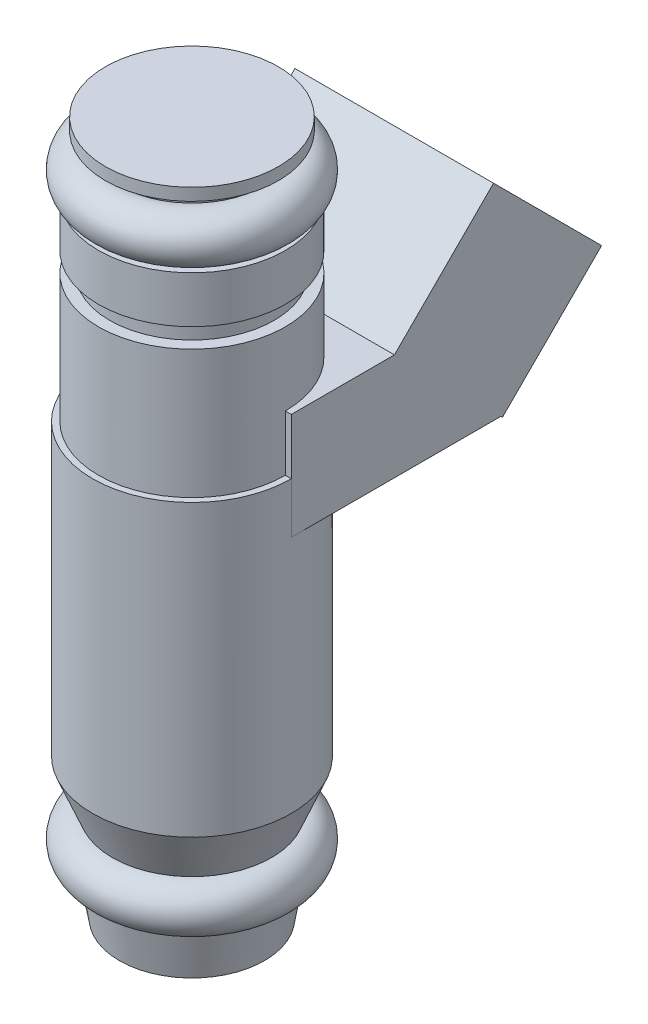
from build123d import *

# Parameters (mm, degrees)
SKETCH3_W           = 13.5
SKETCH3_H           = 10.382914324
BOSS_EXTRUDE1_DEPTH = 9.525
BOSS_EXTRUDE2_START = -14.243138
SKETCH4_W           = 13.5
SKETCH4_H           = 7.234030804
BOSS_EXTRUDE2_DEPTH = 14.243138


with BuildPart() as part:
    # Sketch1 → Revolve1 (revolve)
    with BuildSketch(Plane(origin=(0, 0, 0), x_dir=(0, 0, -1), z_dir=(1, 0, 0))):
        with BuildLine():
            Line((0, 42.48431703), (0, -4.71568297))
            Line((0, -4.71568297), (-4.933645932, -4.71568297))
            Line((-4.933645932, -4.71568297), (-5.5, -1.585086748))
            ThreePointArc((-5.5, -1.585086748), (-6.999396572, 0.043766636), (-5.4125, 1.5875))
            Line((-5.4125, 1.5875), (-6.75, 4.851437808))
            Line((-6.75, 4.851437808), (-6.75, 24.552512087))
            Line((-6.75, 24.552512087), (-6.346345985, 24.552512087))
            Line((-6.346345985, 24.552512087), (-6.346345985, 33.2867))
            Line((-6.346345985, 33.2867), (-5.588, 33.2867))
            Line((-5.588, 33.2867), (-5.588, 34.6075))
            Line((-5.588, 34.6075), (-6.346345985, 34.6075))
            Line((-6.346345985, 34.6075), (-6.346345985, 37.7825))
            Line((-6.346345985, 37.7825), (-5.4125, 37.7825))
            ThreePointArc((-5.4125, 37.7825), (-6.981405369, 39.612264718), (-4.933645932, 40.883557079))
            Line((-4.933645932, 40.883557079), (-4.933645932, 41.654223502))
            Line((-4.933645932, 41.654223502), (-5.880026524, 41.654223502))
            Line((-5.880026524, 41.654223502), (-5.880026524, 42.48431703))
            Line((-5.880026524, 42.48431703), (0, 42.48431703))
        make_face()
    revolve(axis=Axis((0, 42.48431703, 0), (0, -1, 0)))



with BuildPart() as body_2:
    # Sketch3 → Boss-Extrude1 (new body)
    with BuildSketch(Plane(origin=(0, 17.673005927, -17.673005927), x_dir=(1, 0, 0), z_dir=(0, -0.707106781, 0.707106781))):
        with Locations((0, 9.889573108)):
            Rectangle(SKETCH3_W, SKETCH3_H)
    extrude(amount=-BOSS_EXTRUDE1_DEPTH)


with BuildPart() as part_1:
    add(part.part)

    add(body_2.part)  # Boss-Extrude2 merges body 2
    # Sketch4 → Boss-Extrude2 (add)
    with BuildSketch(Plane.XY.offset(BOSS_EXTRUDE2_START)):
        with Locations((0, 24.719889296)):
            Rectangle(SKETCH4_W, SKETCH4_H)
    extrude(amount=BOSS_EXTRUDE2_DEPTH)


solid = part_1.part
